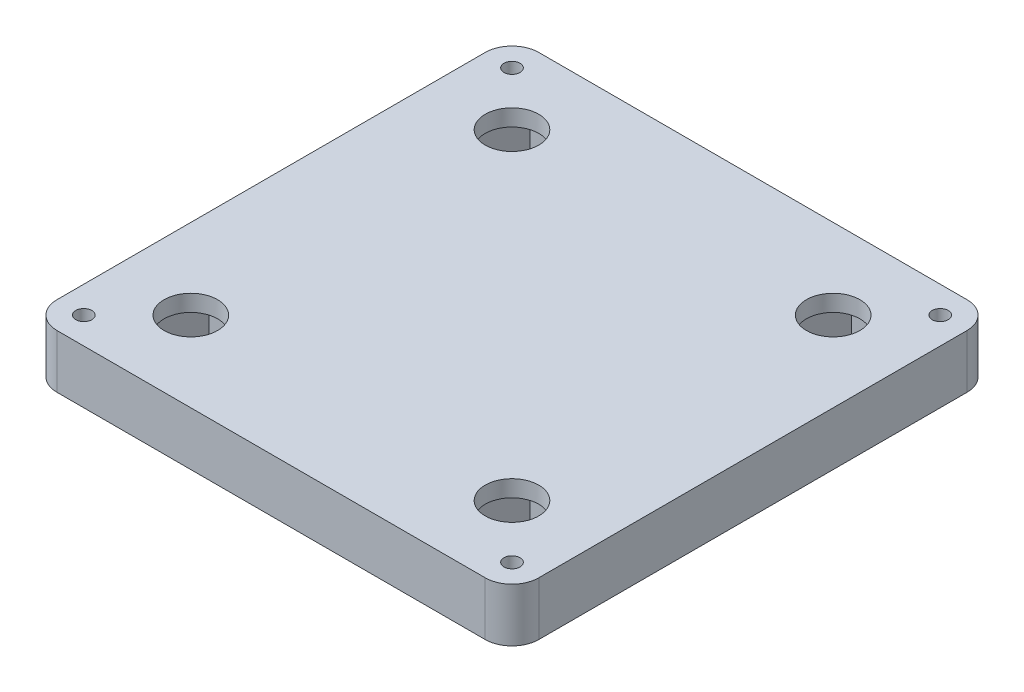
from build123d import *

# Parameters (mm, degrees)
SKETCH1_W           = 90
SKETCH1_H           = 90
BOSS_EXTRUDE1_DEPTH = 10
CUT_EXTRUDE1_DEPTH  = 6.9
SKETCH3_R           = 1.5
CUT_EXTRUDE2_DEPTH  = 11
SKETCH4_R           = 5
CUT_EXTRUDE3_DEPTH  = 11
CUT_EXTRUDE4_DEPTH  = 6.9
FILLET1_R           = 5


with BuildPart() as part:
    # Sketch1 → Boss-Extrude1 (new body)
    with BuildSketch(Plane(origin=(0, 0, 0), x_dir=(1, 0, 0), z_dir=(0, 1, 0))):
        Rectangle(SKETCH1_W, SKETCH1_H)
    extrude(amount=BOSS_EXTRUDE1_DEPTH)

    # Sketch2 → Cut-Extrude1 (cut)
    with BuildSketch(Plane.XZ):
        Polygon((-4.618802154, -8), (4.618802154, -8), (9.237604307, 0), (4.618802154, 8), (-4.618802154, 8), (-9.237604307, 0), align=None)
        with BuildLine():
            Line((-8.754828956, 15.286801604), (-12.02081528, 12.02081528))
            ThreePointArc((-12.02081528, 12.02081528), (12.02081528, 12.02081528), (12.02081528, -12.02081528))
            Line((12.02081528, -12.02081528), (15.286801604, -8.754828956))
            Line((15.286801604, -8.754828956), (24.209642177, -11.145696882))
            Line((24.209642177, -11.145696882), (26.494591989, -19.673245674))
            ThreePointArc((26.494591989, -19.673245674), (23.334523779, 23.334523779), (-19.673245674, 26.494591989))
            Line((-19.673245674, 26.494591989), (-11.145696882, 24.209642177))
            Line((-11.145696882, 24.209642177), (-8.754828956, 15.286801604))
        make_face()
        with BuildLine():
            Line((15.286801604, -8.754828956), (12.02081528, -12.02081528))
            ThreePointArc((12.02081528, -12.02081528), (9.950262871, -15.607117349), (9.950263016, -19.74822225))
            ThreePointArc((9.950263016, -19.74822225), (12.020815311, -23.33452381), (15.607116893, -25.405076066))
            ThreePointArc((15.607116893, -25.405076066), (19.748221753, -25.405076177), (23.334523779, -23.334523779))
            ThreePointArc((23.334523779, -23.334523779), (24.981721996, -21.561854422), (26.494591989, -19.673245674))
            Line((26.494591989, -19.673245674), (24.209642177, -11.145696882))
            Line((24.209642177, -11.145696882), (15.286801604, -8.754828956))
        make_face()
        with BuildLine():
            ThreePointArc((-19.748221967, 9.95026294), (-15.607117207, 9.950262909), (-12.02081528, 12.02081528))
            Line((-12.02081528, 12.02081528), (-8.754828956, 15.286801604))
            Line((-8.754828956, 15.286801604), (-11.145696882, 24.209642177))
            Line((-11.145696882, 24.209642177), (-19.673245674, 26.494591989))
            ThreePointArc((-19.673245674, 26.494591989), (-21.561854422, 24.981721996), (-23.334523779, 23.334523779))
            ThreePointArc((-23.334523779, 23.334523779), (-25.405076135, 19.748221911), (-25.405076151, 15.607117209))
            ThreePointArc((-25.405076151, 15.607117209), (-23.334523822, 12.020815323), (-19.748221967, 9.95026294))
        make_face()
        with BuildLine():
            Line((-26.600510103, 20.068537455), (-25.405076151, 15.607117209))
            ThreePointArc((-25.405076151, 15.607117209), (-25.405076135, 19.748221911), (-23.334523779, 23.334523779))
            Line((-23.334523779, 23.334523779), (-26.600510103, 20.068537455))
        make_face()
        with BuildLine():
            Line((-19.748221967, 9.95026294), (-15.286801604, 8.754828956))
            Line((-15.286801604, 8.754828956), (-12.02081528, 12.02081528))
            ThreePointArc((-12.02081528, 12.02081528), (-15.607117207, 9.950262909), (-19.748221967, 9.95026294))
        make_face()
        with BuildLine():
            Line((-24.209642177, 11.145696882), (-19.748221967, 9.95026294))
            ThreePointArc((-19.748221967, 9.95026294), (-23.334523822, 12.020815323), (-25.405076151, 15.607117209))
            Line((-25.405076151, 15.607117209), (-24.209642177, 11.145696882))
        make_face()
        with BuildLine():
            ThreePointArc((9.950263016, -19.74822225), (9.950262871, -15.607117349), (12.02081528, -12.02081528))
            Line((12.02081528, -12.02081528), (8.754828956, -15.286801604))
            Line((8.754828956, -15.286801604), (9.950263016, -19.74822225))
        make_face()
        with BuildLine():
            ThreePointArc((15.607116893, -25.405076066), (12.020815311, -23.33452381), (9.950263016, -19.74822225))
            Line((9.950263016, -19.74822225), (11.145696882, -24.209642177))
            Line((11.145696882, -24.209642177), (15.607116893, -25.405076066))
        make_face()
        with BuildLine():
            ThreePointArc((23.334523779, -23.334523779), (19.748221753, -25.405076177), (15.607116893, -25.405076066))
            Line((15.607116893, -25.405076066), (20.068537455, -26.600510103))
            Line((20.068537455, -26.600510103), (23.334523779, -23.334523779))
        make_face()
    extrude(amount=-CUT_EXTRUDE1_DEPTH, mode=Mode.SUBTRACT)

    # Sketch3 → Cut-Extrude2 (cut, through all)
    with BuildSketch(Plane(origin=(0, 10, 0), x_dir=(1, 0, 0), z_dir=(0, 1, 0))):
        with Locations((-40, 40)):
            Circle(SKETCH3_R)
        with Locations((40, 40)):
            Circle(SKETCH3_R)
        with Locations((40, -40)):
            Circle(SKETCH3_R)
        with Locations((-40, -40)):
            Circle(SKETCH3_R)
    extrude(amount=-CUT_EXTRUDE2_DEPTH, mode=Mode.SUBTRACT)

    # Sketch4 → Cut-Extrude3 (cut, through all)
    with BuildSketch(Plane(origin=(0, 10, 0), x_dir=(1, 0, 0), z_dir=(0, 1, 0))):
        with Locations((-30, 30)):
            Circle(SKETCH4_R)
        with Locations((30, 30)):
            Circle(SKETCH4_R)
        with Locations((30, -30)):
            Circle(SKETCH4_R)
        with Locations((-30, -30)):
            Circle(SKETCH4_R)
    extrude(amount=-CUT_EXTRUDE3_DEPTH, mode=Mode.SUBTRACT)

    # Sketch6 → Cut-Extrude4 (cut)
    with BuildSketch(Plane.XZ):
        Polygon((-25.381197846, 22), (-20.762395693, 30), (-25.381197846, 38), (-34.618802154, 38), (-39.237604307, 30), (-34.618802154, 22), align=None)
        Polygon((34.618802154, 22), (39.237604307, 30), (34.618802154, 38), (25.381197846, 38), (20.762395693, 30), (25.381197846, 22), align=None)
        Polygon((34.618802154, -38), (39.237604307, -30), (34.618802154, -22), (25.381197846, -22), (20.762395693, -30), (25.381197846, -38), align=None)
        Polygon((-20.762395693, -30), (-25.381197846, -22), (-34.618802154, -22), (-39.237604307, -30), (-34.618802154, -38), (-25.381197846, -38), align=None)
    extrude(amount=-CUT_EXTRUDE4_DEPTH, mode=Mode.SUBTRACT)

    # Fillet1
    fillet1_edges = [part.edges().sort_by_distance(p)[0] for p in [
        (45, 5, 45),
        (-45, 5, 45),
        (-45, 5, -45),
        (45, 5, -45),
    ]]
    fillet(fillet1_edges, radius=FILLET1_R)


solid = part.part
